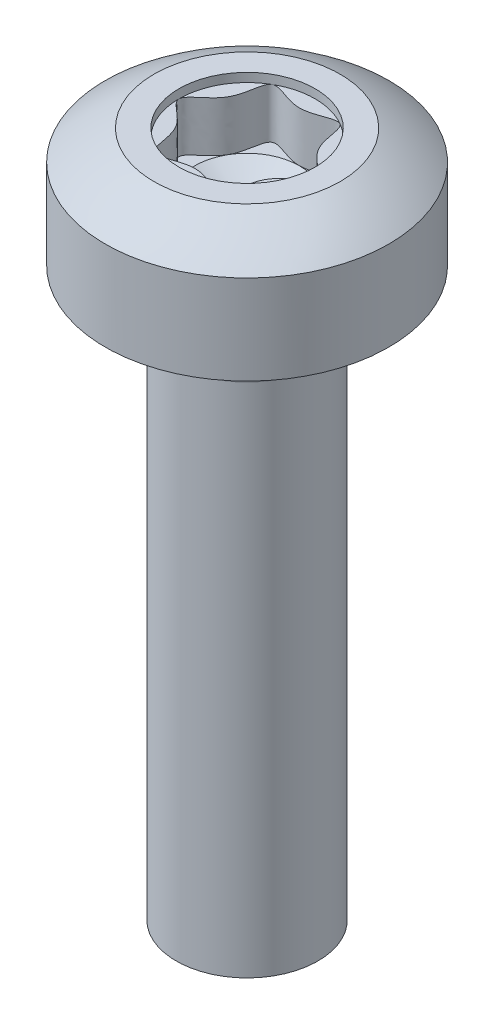
from build123d import *

# Parameters (mm, degrees)
RECESS_CUT_EXTRUDE1_DEPTH = 1.04
SKETCH7_R                 = 1.2
RECESS_CUT_EXTRUDE2_DEPTH = 0.156


with BuildPart() as part:
    # Sketch1 → BODY (revolve)
    with BuildSketch(Plane.XY, mode=Mode.PRIVATE) as body_sk:
        Polygon((0, 0), (1.25, 0), (1.25, 10), (2.5, 10), (2.5, 12.1), (0, 12.1), align=None)
    revolve(body_sk.sketch.rotate(Axis((0, 0, 0), (0, 1, 0)), 90), axis=Axis((0, 0, 0), (0, 1, 0)))

    # Sketch2 → HEAD-CUT (revolve, cut)
    with BuildSketch(Plane.XY, mode=Mode.PRIVATE) as head_cut_sk:
        with BuildLine():
            ThreePointArc((4, 8.452501001), (2.828427125, 11.280928126), (0, 12.452501001))
            Line((0, 12.452501001), (0, 12.934662571))
            Line((0, 12.934662571), (4, 12.934662571))
            Line((4, 12.934662571), (4, 8.452501001))
        make_face()
    revolve(head_cut_sk.sketch.rotate(Axis((0, 0, 0), (0, 1, 0)), 90), axis=Axis((0, 0, 0), (0, 1, 0)), mode=Mode.SUBTRACT)

    # Sketch4 → GAP (revolve, cut)
    with BuildSketch(Plane.XY, mode=Mode.PRIVATE) as gap_sk:
        with BuildLine():
            Line((-1.25, 9.1), (-1.188645175, 9.9))
            ThreePointArc((-1.188645175, 9.9), (-1.20311675, 9.959943063), (-1.25, 10))
            Line((-1.25, 10), (-1.25, 9.1))
        make_face()
    revolve(gap_sk.sketch.rotate(Axis((0, 0, 0), (0, 1, 0)), 270), axis=Axis((0, 0, 0), (0, 1, 0)), mode=Mode.SUBTRACT)

    # Sketch5 → Recess-Cut-Extrude1 (cut)
    with BuildSketch(Plane(origin=(0, 12.1, 0), x_dir=(-1, 0, 0), z_dir=(0, 1, 0))):
        with BuildLine():
            add(Edge.make_bspline(
                [(0, 0.923076923), (-0.246244913, 0.923076923), (-0.738734739, 1.279526102), (-0.645061043, 0.372426167), (-1.477469478, 0), (-0.645061043, -0.372426167), (-0.738734739, -1.279526102), (0, -0.744852334), (0.738734739, -1.279526102), (0.645061043, -0.372426167), (1.477469478, 0), (0.645061043, 0.372426167), (0.738734739, 1.279526102), (0.246244913, 0.923076923), (0, 0.923076923)],
                knots=[0, 0, 0, 0, 0.083333333, 0.166666667, 0.25, 0.333333333, 0.416666667, 0.5, 0.583333333, 0.666666667, 0.75, 0.833333333, 0.916666667, 1, 1, 1, 1], degree=3))
        make_face()
    extrude(amount=-RECESS_CUT_EXTRUDE1_DEPTH, mode=Mode.SUBTRACT)

    # Sketch3 → DRILL-CUT (revolve, cut)
    with BuildSketch(Plane.XY, mode=Mode.PRIVATE) as drill_cut_sk:
        Polygon((0, 10.52706129), (0.923076923, 11.06), (0, 11.06), align=None)
    revolve(drill_cut_sk.sketch.rotate(Axis((0, 0, 0), (0, 1, 0)), 270), axis=Axis((0, 0, 0), (0, 1, 0)), mode=Mode.SUBTRACT)

    # Sketch7 → Recess-Cut-Extrude2 (cut)
    with BuildSketch(Plane(origin=(0, 12.1, 0), x_dir=(-1, 0, 0), z_dir=(0, 1, 0))):
        with Locations(Location((0, 0, 0), (0, 0, 90))):
            Circle(SKETCH7_R)
    extrude(amount=-RECESS_CUT_EXTRUDE2_DEPTH, mode=Mode.SUBTRACT)


solid = part.part
